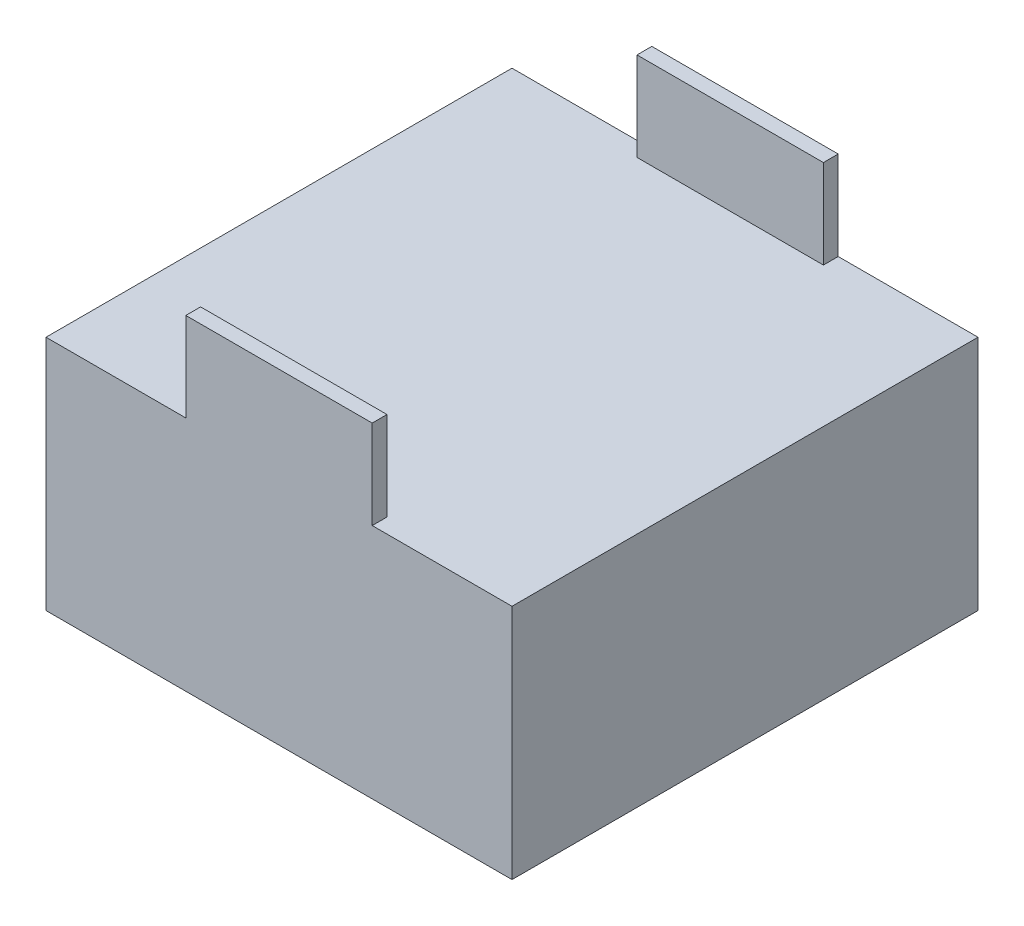
from build123d import *

# Parameters (mm, degrees)
SKETCH1_W           = 49.9999
SKETCH1_H           = 49.9999
BOSS_EXTRUDE1_DEPTH = 25.4
SKETCH2_W           = 20.0000108
SKETCH2_H           = 1.5875
BOSS_EXTRUDE2_DEPTH = 9.525


with BuildPart() as part:
    # Sketch1 → Boss-Extrude1 (new body)
    with BuildSketch(Plane(origin=(0, 0, 0), x_dir=(1, 0, 0), z_dir=(0, 1, 0))):
        with Locations((24.99995, 24.99995)):
            Rectangle(SKETCH1_W, SKETCH1_H)
    extrude(amount=BOSS_EXTRUDE1_DEPTH)

    # Sketch2 → Boss-Extrude2 (add)
    with BuildSketch(Plane(origin=(0, 25.4, 0), x_dir=(1, 0, 0), z_dir=(0, 1, 0))):
        with Locations((24.99995, 0.79375)):
            Rectangle(SKETCH2_W, SKETCH2_H)
        with Locations((24.99995, 49.20615)):
            Rectangle(SKETCH2_W, SKETCH2_H)
    extrude(amount=BOSS_EXTRUDE2_DEPTH)


solid = part.part
